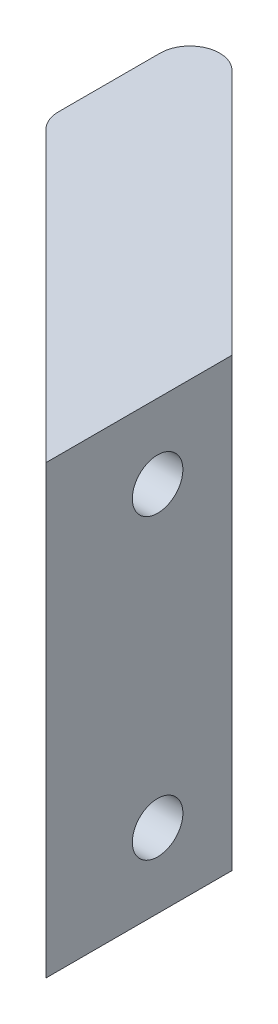
from build123d import *

# Parameters (mm, degrees)
BOSS_EXTRUDE1_DEPTH  = 15
CUT_EXTRUDE1_START   = -4
SKETCH2_R            = 3
CUT_EXTRUDE1_DEPTH   = 32.355339059
M3_CLEARANCE_HOLE1_D = 3.4
FILLET2_R            = 2


with BuildPart() as part:
    # Sketch1 → Boss-Extrude1 (new, symmetric)
    with BuildSketch(Plane(origin=(0, 0, 0), x_dir=(1, 0, 0), z_dir=(0, 1, 0))):
        Polygon((0, 0), (0, -7.5), (-20, 12.5), (-20, 25), (0, 5), align=None)
    extrude(amount=BOSS_EXTRUDE1_DEPTH, both=True)

    # Sketch2 → Cut-Extrude1 (cut, through all)
    with BuildSketch(Plane(origin=(0, 0, 0), x_dir=(0, 0, -1), z_dir=(1, 0, 0)).offset(CUT_EXTRUDE1_START)):
        with Locations((0, 10)):
            Circle(SKETCH2_R)
        with Locations((0, -10)):
            Circle(SKETCH2_R)
    extrude(amount=-CUT_EXTRUDE1_DEPTH, mode=Mode.SUBTRACT)

    # M3 Clearance Hole1 (through all)
    with Locations(Plane.ZY.offset(4)):
        with Locations((0, 10), (0, -10)):
            Hole(M3_CLEARANCE_HOLE1_D / 2)

    # Fillet2
    fillet2_edges = [part.edges().sort_by_distance(p)[0] for p in [
        (-20, 0, -12.5),
        (-20, 0, -25),
    ]]
    fillet(fillet2_edges, radius=FILLET2_R)


solid = part.part
